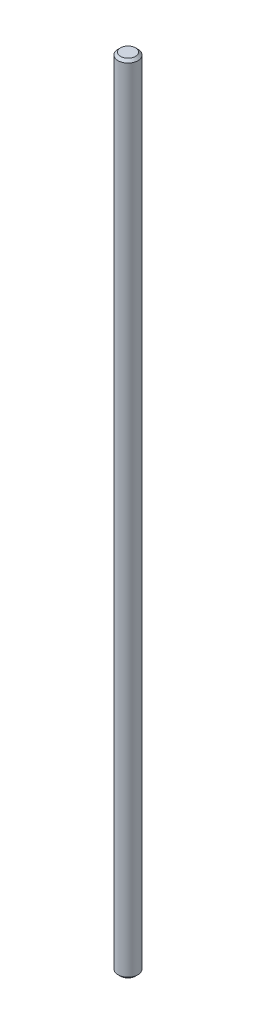
from build123d import *

# Parameters (mm, degrees)
SKETCH1_R           = 2
BOSS_EXTRUDE1_DEPTH = 160
CHAMFER1_SIZE       = 0.5


with BuildPart() as part:
    # Sketch1 → Boss-Extrude1 (new body)
    with BuildSketch(Plane(origin=(0, 0, 0), x_dir=(1, 0, 0), z_dir=(0, 1, 0))):
        Circle(SKETCH1_R)
    extrude(amount=BOSS_EXTRUDE1_DEPTH)

    # Chamfer1
    chamfer1_edges = [part.edges().sort_by_distance(p)[0] for p in [
        (-2, 0, 0),
        (-2, 160, 0),
    ]]
    chamfer(chamfer1_edges, length=CHAMFER1_SIZE)


solid = part.part
